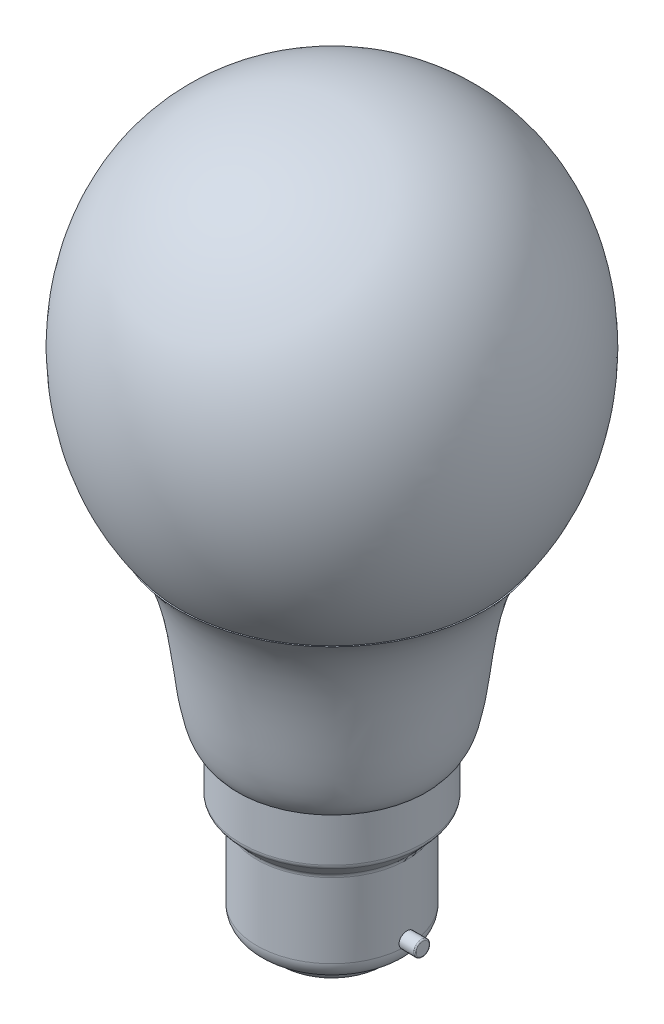
from build123d import *

# Parameters (mm, degrees)
FILLET1_R = 0.2
FILLET2_R = 1


with BuildPart() as part:
    # Sketch2 → Revolve2 (revolve)
    with BuildSketch(Plane.XY):
        with BuildLine():
            Line((0, 60), (0, 30))
            Line((0, 30), (15, 30))
            add(Edge.make_bspline(
                [(15, 30), (19.4, 34.3), (16.4, 51.5), (24.51148918, 60)],
                knots=[0, 0, 0, 0, 1, 1, 1, 1], degree=3))
            Line((24.51148918, 60), (0, 60))
        make_face()
    revolve(axis=Axis((0, 30, 0), (0, 1, 0)))

    # Sketch4 → Revolve3 (revolve)
    with BuildSketch(Plane.XY):
        with BuildLine():
            Line((0, 60), (0, 118))
            add(Edge.make_bspline(
                [(0, 118), (32.962086546, 118), (40, 80), (24.3, 60)],
                knots=[0, 0, 0, 0, 1, 1, 1, 1], degree=3))
            Line((24.3, 60), (0, 60))
        make_face()
    revolve(axis=Axis((0, 60, 0), (0, 1, 0)))

    # Sketch5 → Revolve4 (revolve)
    with BuildSketch(Plane.XY):
        with BuildLine():
            Line((0, 30), (0, 4.3))
            Line((0, 4.3), (9, 4.3))
            ThreePointArc((9, 4.3), (11.121320344, 5.178679656), (12, 7.3))
            Line((12, 7.3), (12, 19.6))
            Line((12, 19.6), (14.5, 22.3))
            Line((14.5, 22.3), (14.5, 30))
            Line((14.5, 30), (0, 30))
        make_face()
        with BuildLine():
            Line((0, 4.3), (0, 2))
            Line((0, 2), (6.492425982, 2))
            ThreePointArc((6.492425982, 2), (8.193743667, 2.662079872), (9, 4.3))
            Line((9, 4.3), (0, 4.3))
        make_face()
    revolve(axis=Axis((0, 0, 0), (0, 1, 0)))

    # Sketch6 → Revolve5 (revolve)
    with BuildSketch(Plane.XY):
        Polygon((-14.5, 8.364592551), (14.5, 8.139603601), (14.5, 9.377042827), (-14.5, 9.377042827), align=None)
    revolve(axis=Axis((-14.5, 8.364592551, 0), (0.999969906, -0.007758006, 0)))

    # Fillet1
    fillet1_edges = [part.edges().sort_by_distance(p)[0] for p in [
        (14.480800455, 6.902313329, 0),
        (-14.515708718, 7.352264147, 0),
    ]]
    fillet(fillet1_edges, radius=FILLET1_R)

    # Fillet2
    fillet2_edges = [part.edges().sort_by_distance(p)[0] for p in [
        (-12, 19.6, 0),
        (-14.5, 22.3, 0),
    ]]
    fillet(fillet2_edges, radius=FILLET2_R)


solid = part.part
